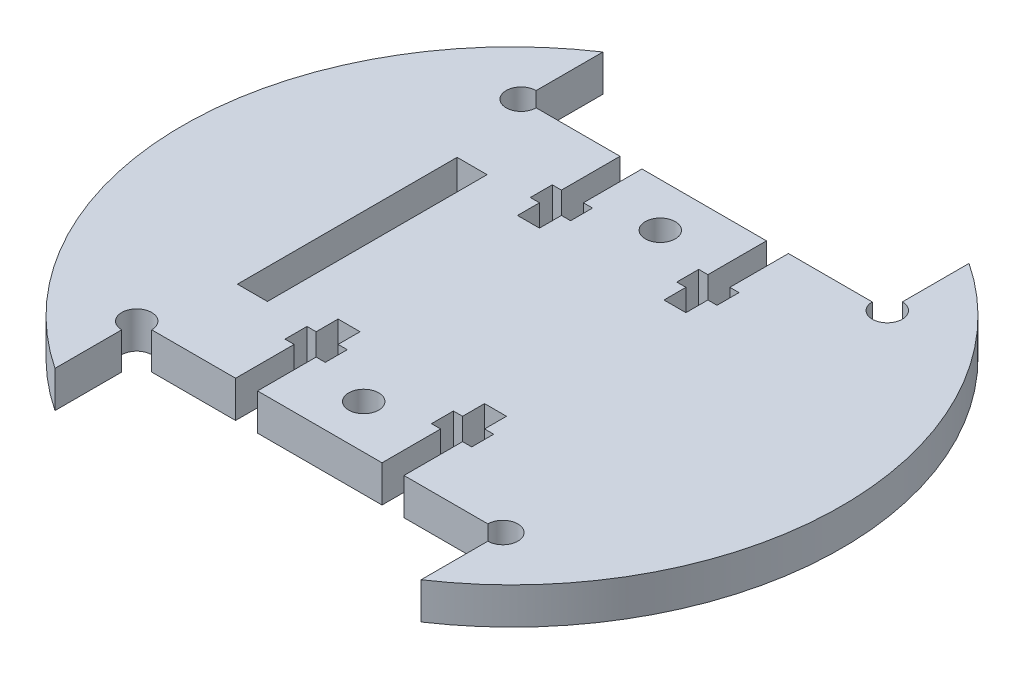
from build123d import *

# Parameters (mm, degrees)
ESTRUSIONE_ESTRUSIONE1_DEPTH = 2.5
CORTAR_EXTRUIR4_DEPTH        = 10
CROQUIS2_R                   = 2.05
CORTAR_EXTRUIR5_DEPTH        = 6
CUT_EXTRUDE1_REACH           = 7
SKETCH3_W                    = 4.1
SKETCH3_H                    = 30
CUT_EXTRUDE2_REACH           = 7
SKETCH4_R                    = 2.05


with BuildPart() as part:
    # Schizzo1 → Estrusione-Estrusione1 (new body, symmetric)
    with BuildSketch(Plane(origin=(0, 0, 0), x_dir=(1, 0, 0), z_dir=(0, 1, 0))):
        with BuildLine():
            Line((-25, 37.416573868), (-25, 26.25))
            Line((-25, 26.25), (25, 26.25))
            Line((25, 26.25), (25, 37.416573868))
            ThreePointArc((25, 37.416573868), (45, 0), (25, -37.416573868))
            Line((25, -37.416573868), (25, -26.25))
            Line((25, -26.25), (-25, -26.25))
            Line((-25, -26.25), (-25, -37.416573868))
            ThreePointArc((-25, -37.416573868), (-45, 0), (-25, 37.416573868))
        make_face()
    extrude(amount=ESTRUSIONE_ESTRUSIONE1_DEPTH, both=True)

    # Croquis1 → Cortar-Extruir4 (cut)
    with BuildSketch(Plane.XZ.offset(2.5)):
        Polygon((-8.5, 26.25), (-11.5, 26.25), (-11.5, 18.25), (-12.75, 18.25), (-12.75, 15.25), (-11.5, 15.25), (-11.5, 12.25), (-8.5, 12.25), (-8.5, 15.25), (-7.25, 15.25), (-7.25, 18.25), (-8.5, 18.25), align=None)
        Polygon((11.5, 26.25), (8.5, 26.25), (8.5, 18.25), (7.25, 18.25), (7.25, 15.25), (8.5, 15.25), (8.5, 12.25), (11.5, 12.25), (11.5, 15.25), (12.75, 15.25), (12.75, 18.25), (11.5, 18.25), align=None)
        Polygon((8.5, -12.25), (8.5, -15.25), (7.25, -15.25), (7.25, -18.25), (8.5, -18.25), (8.5, -26.25), (11.5, -26.25), (11.5, -18.25), (12.75, -18.25), (12.75, -15.25), (11.5, -15.25), (11.5, -12.25), align=None)
        Polygon((-11.5, -12.25), (-11.5, -15.25), (-12.75, -15.25), (-12.75, -18.25), (-11.5, -18.25), (-11.5, -26.25), (-8.5, -26.25), (-8.5, -18.25), (-7.25, -18.25), (-7.25, -15.25), (-8.5, -15.25), (-8.5, -12.25), align=None)
    extrude(amount=-CORTAR_EXTRUIR4_DEPTH, mode=Mode.SUBTRACT)

    # Croquis2 → Cortar-Extruir5 (cut, through all)
    with BuildSketch(Plane(origin=(0, 2.5, 0), x_dir=(1, 0, 0), z_dir=(0, 1, 0))):
        with Locations((0, 20.25)):
            Circle(CROQUIS2_R)
        with Locations((0, -20.25)):
            Circle(CROQUIS2_R)
    extrude(amount=-CORTAR_EXTRUIR5_DEPTH, mode=Mode.SUBTRACT)

    # Sketch3 → Cut-Extrude1 (cut, up to next)
    with BuildSketch(Plane(origin=(0, 2.5, 0), x_dir=(1, 0, 0), z_dir=(0, 1, 0)), mode=Mode.PRIVATE) as cut_extrude1_sk1:
        with Locations((-20.45, 0)):
            Rectangle(SKETCH3_W, SKETCH3_H)
    cut_extrude1_tool1 = extrude(cut_extrude1_sk1.sketch, amount=-CUT_EXTRUDE1_REACH, mode=Mode.PRIVATE) & part.part
    add(cut_extrude1_tool1.solids().sort_by_distance((-20.45, 2.5, 0))[0], mode=Mode.SUBTRACT)

    # Sketch4 → Cut-Extrude2 (cut, up to next)
    with BuildSketch(Plane(origin=(0, 2.5, 0), x_dir=(1, 0, 0), z_dir=(0, 1, 0)), mode=Mode.PRIVATE) as cut_extrude2_sk1:
        with Locations((-25, 26.25)):
            Circle(SKETCH4_R)
    cut_extrude2_tool1 = extrude(cut_extrude2_sk1.sketch, amount=-CUT_EXTRUDE2_REACH, mode=Mode.PRIVATE) & part.part
    add(cut_extrude2_tool1.solids().sort_by_distance((-25, 2.5, -26.25))[0], mode=Mode.SUBTRACT)
    # Sketch4 → Cut-Extrude2 (cut, up to next)
    with BuildSketch(Plane(origin=(0, 2.5, 0), x_dir=(1, 0, 0), z_dir=(0, 1, 0)), mode=Mode.PRIVATE) as cut_extrude2_sk2:
        with Locations((-25, -26.25)):
            Circle(SKETCH4_R)
    cut_extrude2_tool2 = extrude(cut_extrude2_sk2.sketch, amount=-CUT_EXTRUDE2_REACH, mode=Mode.PRIVATE) & part.part
    add(cut_extrude2_tool2.solids().sort_by_distance((-25, 2.5, 26.25))[0], mode=Mode.SUBTRACT)
    # Sketch4 → Cut-Extrude2 (cut, up to next)
    with BuildSketch(Plane(origin=(0, 2.5, 0), x_dir=(1, 0, 0), z_dir=(0, 1, 0)), mode=Mode.PRIVATE) as cut_extrude2_sk3:
        with Locations((25, -26.25)):
            Circle(SKETCH4_R)
    cut_extrude2_tool3 = extrude(cut_extrude2_sk3.sketch, amount=-CUT_EXTRUDE2_REACH, mode=Mode.PRIVATE) & part.part
    add(cut_extrude2_tool3.solids().sort_by_distance((25, 2.5, 26.25))[0], mode=Mode.SUBTRACT)
    # Sketch4 → Cut-Extrude2 (cut, up to next)
    with BuildSketch(Plane(origin=(0, 2.5, 0), x_dir=(1, 0, 0), z_dir=(0, 1, 0)), mode=Mode.PRIVATE) as cut_extrude2_sk4:
        with Locations((25, 26.25)):
            Circle(SKETCH4_R)
    cut_extrude2_tool4 = extrude(cut_extrude2_sk4.sketch, amount=-CUT_EXTRUDE2_REACH, mode=Mode.PRIVATE) & part.part
    add(cut_extrude2_tool4.solids().sort_by_distance((25, 2.5, -26.25))[0], mode=Mode.SUBTRACT)


solid = part.part
